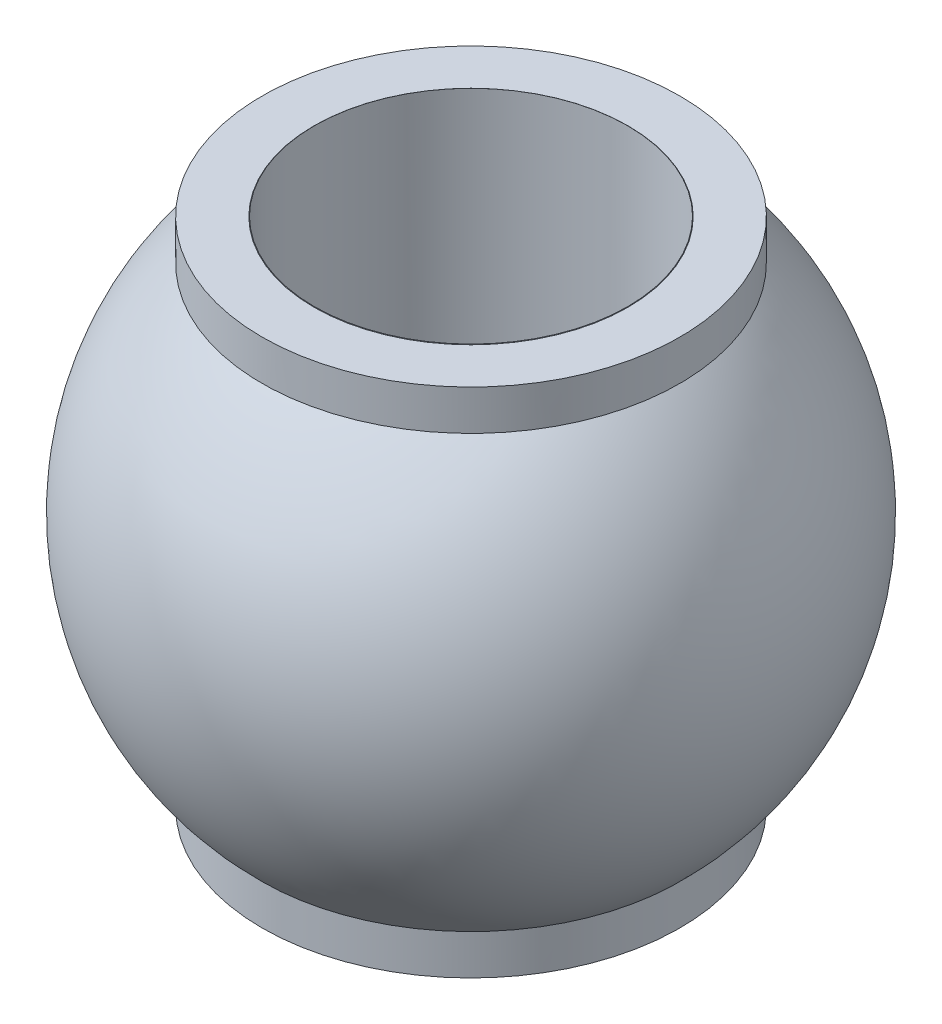
from build123d import *

# Parameters (mm, degrees)
SKETCH2_R           = 2
SKETCH2_R_2         = 1.5
BOSS_EXTRUDE1_DEPTH = 2.45
SKETCH2_3_R         = 1.5
CUT_EXTRUDE1_DEPTH  = 3


with BuildPart() as part:
    # Sketch1 → Revolve1 (revolve)
    with BuildSketch(Plane.XY):
        with BuildLine():
            Line((0, -2.875), (0, 2.875))
            ThreePointArc((0, 2.875), (-2.875, 0), (0, -2.875))
        make_face()
    revolve(axis=Axis((0, 55, 0), (0, -1, 0)))

    # Sketch2 → Boss-Extrude1 (add, symmetric)
    with BuildSketch(Plane(origin=(0, 0, 0), x_dir=(1, 0, 0), z_dir=(0, 1, 0))):
        Circle(SKETCH2_R)
        Circle(SKETCH2_R_2, mode=Mode.SUBTRACT)
    extrude(amount=BOSS_EXTRUDE1_DEPTH, both=True)

    # Sketch2_3 → Cut-Extrude1 (cut, symmetric)
    with BuildSketch(Plane(origin=(0, 0, 0), x_dir=(1, 0, 0), z_dir=(0, 1, 0))):
        Circle(SKETCH2_3_R)
    extrude(amount=CUT_EXTRUDE1_DEPTH, both=True, mode=Mode.SUBTRACT)


solid = part.part
